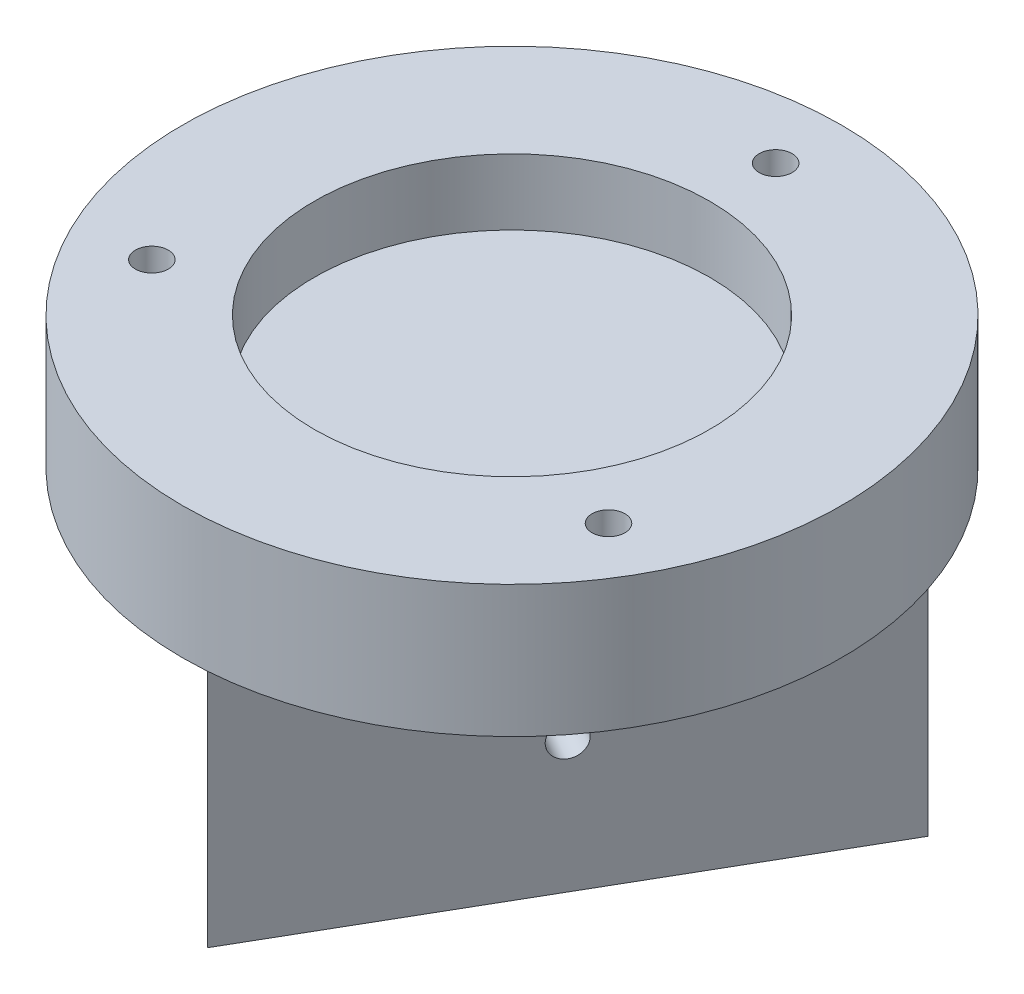
from build123d import *

# Parameters (mm, degrees)
SKETCH1_R               = 63.5
BOSS_EXTRUDE1_DEPTH     = 25.4
SKETCH2_R               = 38.1
CUT_EXTRUDE1_DEPTH      = 12.7
BOSS_EXTRUDE2_DEPTH     = 50.8
SKETCH5_R               = 3.175
CUT_EXTRUDE2_DEPTH      = 1
CUT_EXTRUDE2_DEPTH_BACK = 77.2
SKETCH8_R               = 3.175
CUT_EXTRUDE3_DEPTH      = 15.24
SKETCH7_R               = 3.175
CUT_EXTRUDE5_DEPTH      = 15.24
SKETCH6_R               = 3.175
CUT_EXTRUDE6_DEPTH      = 15.24


with BuildPart() as part:
    # Sketch1 → Boss-Extrude1 (new body)
    with BuildSketch(Plane(origin=(0, 0, 0), x_dir=(1, 0, 0), z_dir=(0, 1, 0))):
        Circle(SKETCH1_R)
    extrude(amount=BOSS_EXTRUDE1_DEPTH)

    # Sketch2 → Cut-Extrude1 (cut)
    with BuildSketch(Plane(origin=(0, 25.4, 0), x_dir=(1, 0, 0), z_dir=(0, 1, 0))):
        Circle(SKETCH2_R)
    extrude(amount=-CUT_EXTRUDE1_DEPTH, mode=Mode.SUBTRACT)

    # Sketch4 → Boss-Extrude2 (add)
    with BuildSketch(Plane.XZ):
        Polygon((50.8, -29.329393675), (0, 58.65878735), (-50.8, -29.329393675), align=None)
    extrude(amount=BOSS_EXTRUDE2_DEPTH)

    # Sketch5 → Cut-Extrude2 (cut, two sides)
    with BuildSketch(Plane(origin=(0, 25.4, 0), x_dir=(1, 0, 0), z_dir=(0, 1, 0))) as cut_extrude2_sk:
        with Locations((0, 50.8)):
            Circle(SKETCH5_R)
        with Locations((43.994090512, -25.4)):
            Circle(SKETCH5_R)
        with Locations((-43.994090512, -25.4)):
            Circle(SKETCH5_R)
    extrude(amount=CUT_EXTRUDE2_DEPTH, mode=Mode.SUBTRACT)
    extrude(cut_extrude2_sk.sketch, amount=-CUT_EXTRUDE2_DEPTH_BACK, mode=Mode.SUBTRACT)

    # Sketch8 → Cut-Extrude3 (cut)
    with BuildSketch(Plane(origin=(-25.4, 0, 14.664696837), x_dir=(0.5, 0, 0.866025404), z_dir=(-0.866025404, 0, 0.5))):
        with Locations((0, -25.4)):
            Circle(SKETCH8_R)
    extrude(amount=-CUT_EXTRUDE3_DEPTH, mode=Mode.SUBTRACT)

    # Sketch7 → Cut-Extrude5 (cut)
    with BuildSketch(Plane(origin=(3.754579306, 0, -29.329393675), x_dir=(1, 0, 0), z_dir=(0, 0, 1))):
        with Locations((-3.754579306, -25.4)):
            Circle(SKETCH7_R)
    extrude(amount=CUT_EXTRUDE5_DEPTH, mode=Mode.SUBTRACT)

    # Sketch6 → Cut-Extrude6 (cut)
    with BuildSketch(Plane(origin=(25.4, 0, 14.664696837), x_dir=(0.5, 0, -0.866025404), z_dir=(0.866025404, 0, 0.5))):
        with Locations((0, -25.4)):
            Circle(SKETCH6_R)
    extrude(amount=-CUT_EXTRUDE6_DEPTH, mode=Mode.SUBTRACT)


solid = part.part
